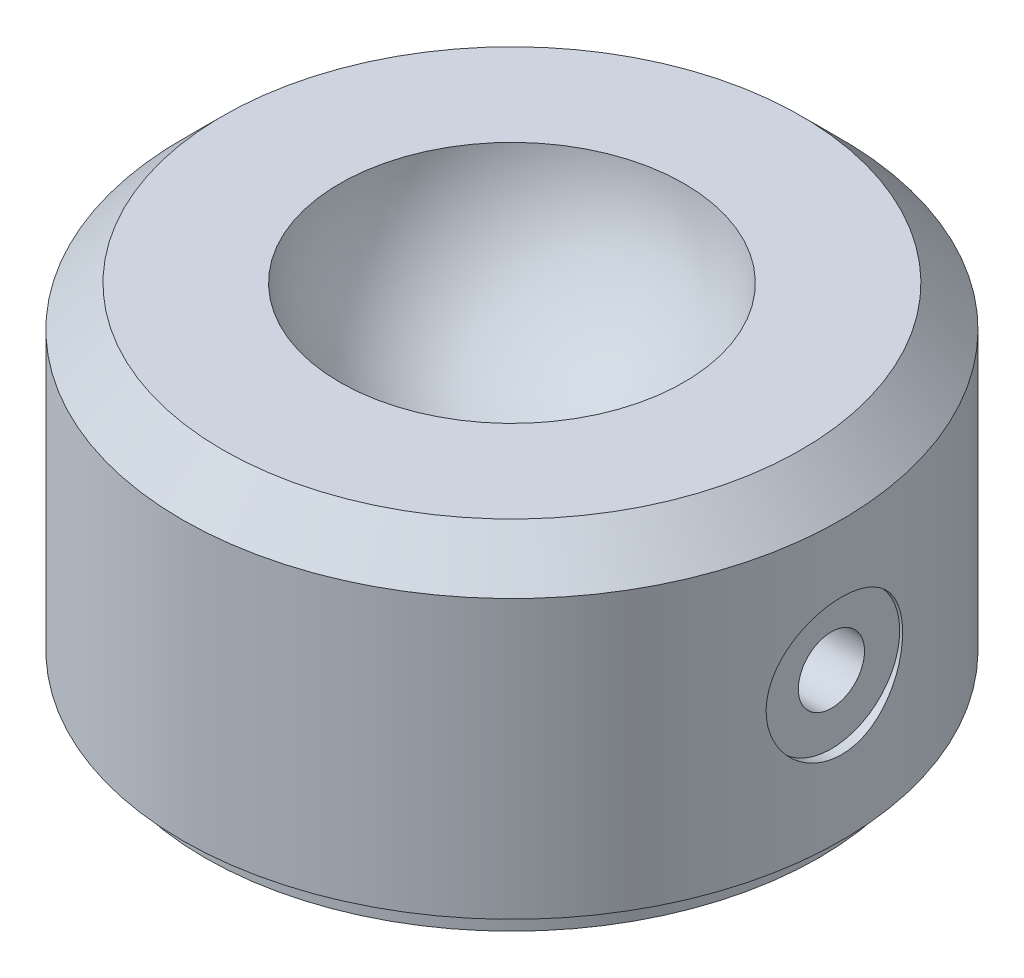
from build123d import *

# Parameters (mm, degrees)
SKETCH1_R                          = 12.446
EXTRUDE1_DEPTH                     = 6.0071
CHAMFER1_SIZE                      = 1.524
SKETCH2_R                          = 11.5951
EXTRUDE2_DEPTH                     = 0.99076
SKETCH3_R                          = 1.5875
EXTRUDE3_DEPTH                     = 6.3754
F_5_16_0_3125_DIAMETER_HOLE2_D     = 5.1562
F_5_16_0_3125_DIAMETER_HOLE2_DEPTH = 0.381
M3X0_5_TAPPED_HOLE1_D              = 2.5
M3X0_5_TAPPED_HOLE1_DEPTH          = 5.3086
M3X0_5_TAPPED_HOLE1_TIP            = 0.751075774


with BuildPart() as part:
    # Sketch1 → Extrude1 (new body, symmetric)
    with BuildSketch(Plane(origin=(0, 0, 0), x_dir=(1, 0, 0), z_dir=(0, 1, 0))):
        with Locations(Location((0, 0, 0), (0, 0, 270))):  # turned: the seam where the file's is
            Circle(SKETCH1_R)
    extrude(amount=EXTRUDE1_DEPTH, both=True)

    # Chamfer1
    chamfer1_edges = [part.edges().sort_by_distance(p)[0] for p in [
        (0, 6.0071, -12.446),
    ]]
    chamfer(chamfer1_edges, length=CHAMFER1_SIZE)

    # Sketch2 → Extrude2 (add)
    with BuildSketch(Plane.XZ.offset(6.0071)):
        with Locations(Location((0, 0, 0), (0, 0, 90))):  # turned: the seam where the file's is
            Circle(SKETCH2_R)
    extrude(amount=EXTRUDE2_DEPTH)

    # Sketch3 → Extrude3 (cut)
    with BuildSketch(Plane(origin=(0, 6.0071, 0), x_dir=(1, 0, 0), z_dir=(0, 1, 0))):
        with Locations(Location((0, 0, 0), (0, 0, 270))):  # turned: the seam where the file's is
            Circle(SKETCH3_R)
    extrude(amount=-EXTRUDE3_DEPTH, mode=Mode.SUBTRACT)

    # Sketch4 → Cut-Revolve1 (revolve, cut)
    with BuildSketch(Plane.XY):
        with BuildLine():
            Line((0, 13.035099954), (0, -0.004899954))
            ThreePointArc((0, -0.004899954), (6.519999954, 6.5151), (0, 13.035099954))
        make_face()
    revolve(axis=Axis((0, 13.035099954, 0), (0, -1, 0)), mode=Mode.SUBTRACT)

    # 5/16 (0.3125) Diameter Hole2
    with Locations(Plane(origin=(12.446, 0, 0), x_dir=(0, 0, -1), z_dir=(1, 0, 0))):
        with Locations((0, -0.6223)):
            Hole(F_5_16_0_3125_DIAMETER_HOLE2_D / 2, depth=F_5_16_0_3125_DIAMETER_HOLE2_DEPTH)

    # M3x0.5 Tapped Hole1
    with Locations(Plane(origin=(12.065, 0, 0), x_dir=(0, 0, -1), z_dir=(1, 0, 0))):
        with Locations((0, -0.6223)):
            Hole(M3X0_5_TAPPED_HOLE1_D / 2, depth=M3X0_5_TAPPED_HOLE1_DEPTH)
            with Locations((0, 0, -(M3X0_5_TAPPED_HOLE1_DEPTH + M3X0_5_TAPPED_HOLE1_TIP / 2))):  # 118° drill point
                Cone(0, M3X0_5_TAPPED_HOLE1_D / 2, M3X0_5_TAPPED_HOLE1_TIP, mode=Mode.SUBTRACT)


solid = part.part
